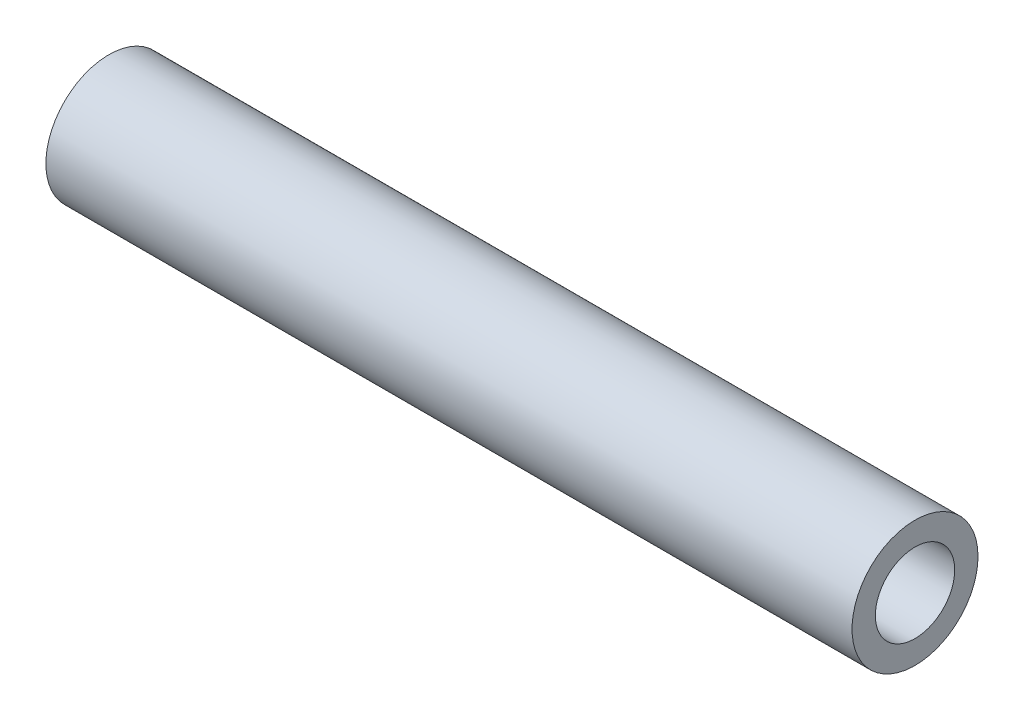
from build123d import *

# Parameters (mm, degrees)
SKETCH1_R           = 3.96875
BOSS_EXTRUDE1_DEPTH = 25.4
SKETCH2_R           = 2.5
CUT_EXTRUDE1_DEPTH  = 12.7


with BuildPart() as part:
    # Sketch1 → Boss-Extrude1 (new body, symmetric)
    with BuildSketch(Plane(origin=(0, 0, 0), x_dir=(0, 0, -1), z_dir=(1, 0, 0))):
        Circle(SKETCH1_R)
    extrude(amount=BOSS_EXTRUDE1_DEPTH, both=True)

    # Sketch2 → Cut-Extrude1 (cut)
    with BuildSketch(Plane(origin=(25.4, 0, 0), x_dir=(0, 0, -1), z_dir=(1, 0, 0))):
        Circle(SKETCH2_R)
    cut_extrude1 = extrude(amount=-CUT_EXTRUDE1_DEPTH, mode=Mode.SUBTRACT)

    # Mirror1: Cut-Extrude1 across plane
    add(cut_extrude1.mirror(Plane(origin=(0, 0, 0), x_dir=(0, 0, 1), z_dir=(1, 0, 0))), mode=Mode.SUBTRACT)


solid = part.part
